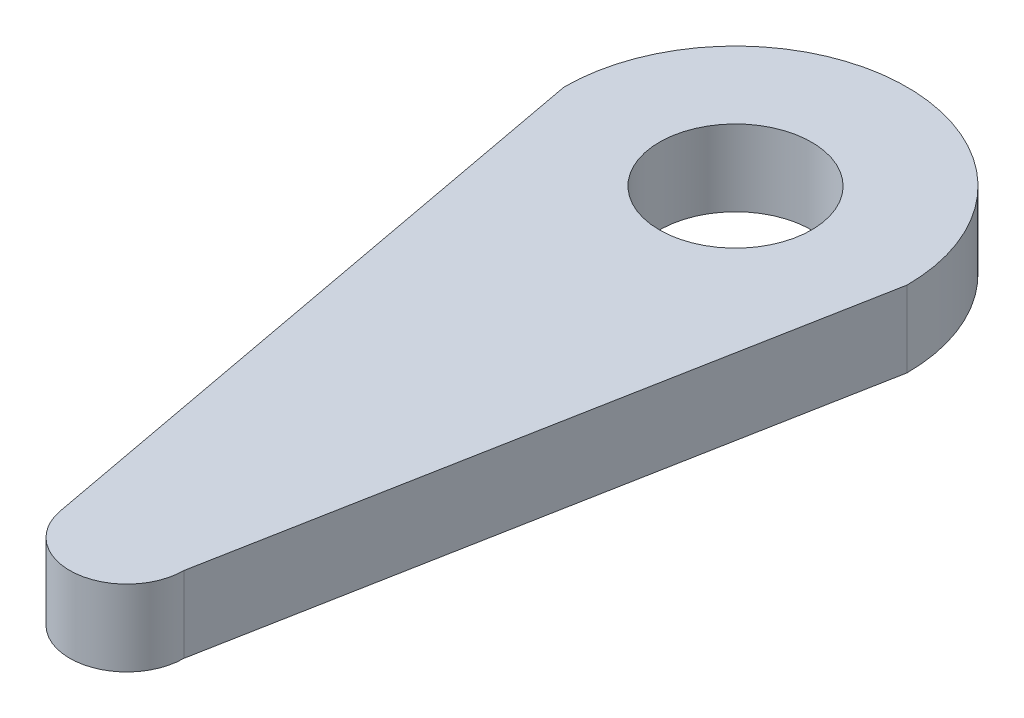
from build123d import *

# Parameters (mm, degrees)
EXTRUDE_1_DEPTH     = 2
SKETCH_2_R          = 2
CUT_EXTRUDE_1_DEPTH = 2


with BuildPart() as part:
    # 草图1 → 凸台-拉伸1 (new body)
    with BuildSketch(Plane(origin=(0, 0, 0), x_dir=(1, 0, 0), z_dir=(0, 1, 0))):
        with BuildLine():
            Line((-4.507909161, 0), (-1.477242174, -16.275084839))
            ThreePointArc((-1.477242174, -16.275084839), (0.138127237, -17.496274365), (1.502636386, -16))
            Line((1.502636386, -16), (4.507909161, 0))
            ThreePointArc((4.507909161, 0), (0, 4.507909161), (-4.507909161, 0))
        make_face()
    extrude(amount=EXTRUDE_1_DEPTH)

    # 草图2 → 切除-拉伸1 (cut)
    with BuildSketch(Plane(origin=(0, 2, 0), x_dir=(1, 0, 0), z_dir=(0, 1, 0))):
        Circle(SKETCH_2_R)
    extrude(amount=-CUT_EXTRUDE_1_DEPTH, mode=Mode.SUBTRACT)


solid = part.part
